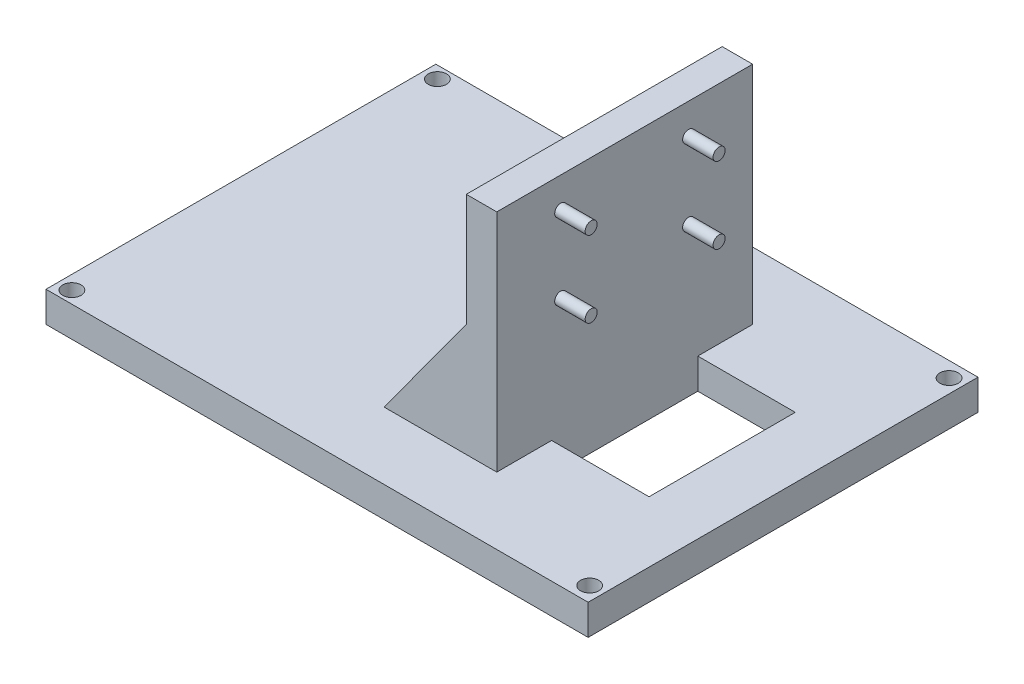
from build123d import *

# Parameters (mm, degrees)
SKETCH1_R           = 1.5
BOSS_EXTRUDE1_DEPTH = 5
SKETCH1_3_W         = 10
SKETCH1_3_H         = 24
CUT_EXTRUDE1_DEPTH  = 56.038622803
SKETCH1_4_W         = 5
SKETCH1_4_H         = 42
BOSS_EXTRUDE2_DEPTH = 42
BOSS_EXTRUDE3_DEPTH = 21
SKETCH4_W           = 24
SKETCH4_H           = 5
CUT_EXTRUDE2_DEPTH  = 6
SKETCH5_R           = 0.99
BOSS_EXTRUDE4_DEPTH = 5


with BuildPart() as part:
    # Sketch1 → Boss-Extrude1 (new body)
    with BuildSketch(Plane(origin=(0, 0, 0), x_dir=(1, 0, 0), z_dir=(0, 1, 0))):
        Polygon((-44.5, -32), (44.5, -32), (44.5, -12), (44.5, 12), (44.5, 32), (-44.5, 32), align=None)
        with Locations((-42.25, -30)):
            Circle(SKETCH1_R, mode=Mode.SUBTRACT)
        with Locations((42.25, -29.5)):
            Circle(SKETCH1_R, mode=Mode.SUBTRACT)
        with Locations((-42.25, 30)):
            Circle(SKETCH1_R, mode=Mode.SUBTRACT)
        with Locations((42.25, 29.5)):
            Circle(SKETCH1_R, mode=Mode.SUBTRACT)
    extrude(amount=BOSS_EXTRUDE1_DEPTH)

    # Sketch1_3 → Cut-Extrude1 (cut, through all)
    with BuildSketch(Plane(origin=(0, 0, 0), x_dir=(1, 0, 0), z_dir=(0, 1, 0))):
        with Locations((29.5, 0)):
            Rectangle(SKETCH1_3_W, SKETCH1_3_H)
    extrude(amount=CUT_EXTRUDE1_DEPTH, mode=Mode.SUBTRACT)

    # Sketch1_4 → Boss-Extrude2 (add)
    with BuildSketch(Plane(origin=(0, 0, 0), x_dir=(1, 0, 0), z_dir=(0, 1, 0))):
        with Locations((16, 0)):
            Rectangle(SKETCH1_4_W, SKETCH1_4_H)
    extrude(amount=BOSS_EXTRUDE2_DEPTH)

    # Sketch3 → Boss-Extrude3 (add, symmetric)
    with BuildSketch(Plane.XY):
        Polygon((13.5, 23.5), (0, 5), (13.5, 5), align=None)
    extrude(amount=BOSS_EXTRUDE3_DEPTH, both=True)

    # Sketch4 → Cut-Extrude2 (cut)
    with BuildSketch(Plane(origin=(24.5, 0, 0), x_dir=(0, 0, -1), z_dir=(1, 0, 0))):
        with Locations((0, 2.5)):
            Rectangle(SKETCH4_W, SKETCH4_H)
    extrude(amount=-CUT_EXTRUDE2_DEPTH, mode=Mode.SUBTRACT)

    # Sketch5 → Boss-Extrude4 (add)
    with BuildSketch(Plane(origin=(18.5, 0, 0), x_dir=(0, 0, -1), z_dir=(1, 0, 0))):
        with Locations((-10.5, 37)):
            Circle(SKETCH5_R)
        with Locations((10.5, 37)):
            Circle(SKETCH5_R)
        with Locations((10.5, 24.5)):
            Circle(SKETCH5_R)
        with Locations((-10.5, 24.5)):
            Circle(SKETCH5_R)
    extrude(amount=BOSS_EXTRUDE4_DEPTH)


solid = part.part
